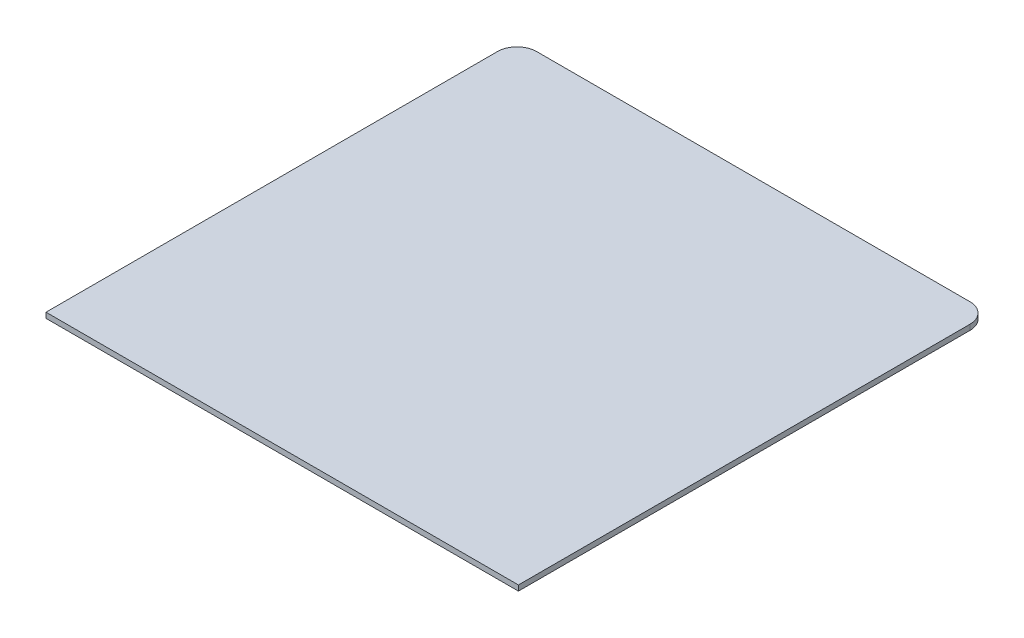
from build123d import *

# Parameters (mm, degrees)
BOSS_EXTRUDE1_DEPTH = 110


with BuildPart() as part:
    # Sketch1 → Boss-Extrude1 (new body)
    with BuildSketch(Plane(origin=(0, 0, 0), x_dir=(1, 0, 0), z_dir=(0, 1, 0))):
        with BuildLine():
            Line((0, 0), (9680, 0))
            Line((9680, 0), (9680, 9252))
            ThreePointArc((9680, 9252), (9562.842712475, 9534.842712475), (9280, 9652))
            Line((9280, 9652), (400, 9652))
            ThreePointArc((400, 9652), (117.157287525, 9534.842712475), (0, 9252))
            Line((0, 9252), (0, 0))
        make_face()
    extrude(amount=BOSS_EXTRUDE1_DEPTH)


solid = part.part
